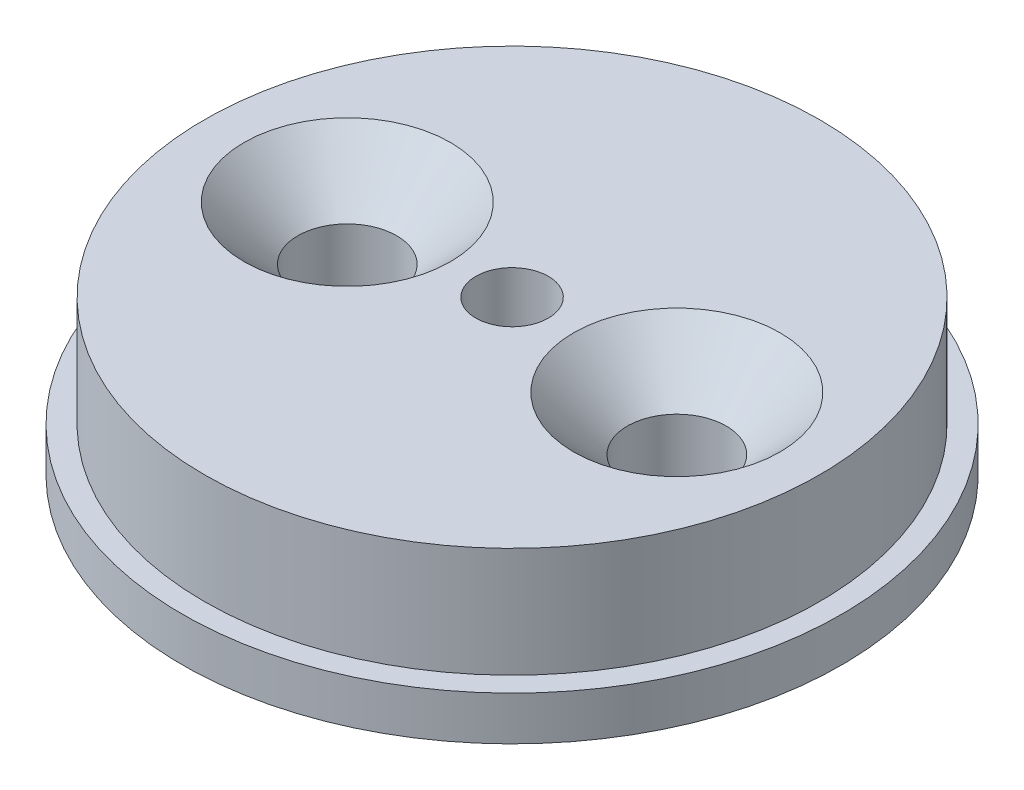
from build123d import *

# Parameters (mm, degrees)
HOLE_WIZARD_M4_1_D           = 4.5
HOLE_WIZARD_M4_1_DEPTH       = 7
HOLE_WIZARD_M4_1_CSINK_D     = 9.4
HOLE_WIZARD_M4_1_CSINK_ANGLE = 90
SKETCH_4_R                   = 3.75
CUT_EXTRUDE_M4_DEPTH         = 3
HOLE_WIZARD_M4_1_2_D         = 3.3
HOLE_WIZARD_M4_1_2_DEPTH     = 4


with BuildPart() as part:
    # 스케치1 → 회전1 (revolve)
    with BuildSketch(Plane.XY):
        Polygon((0, 0), (-15, 0), (-15, 2), (-14, 2), (-14, 7), (0, 7), align=None)
    revolve(axis=Axis((0, 0, 0), (0, 1, 0)))

    # Hole Wizard M4 _ _ _ _1
    with Locations(Plane(origin=(0, 7, 0), x_dir=(1, 0, 0), z_dir=(0, 1, 0))):
        with Locations((-7.5, 0), (7.5, 0)):
            CounterSinkHole(HOLE_WIZARD_M4_1_D / 2, HOLE_WIZARD_M4_1_CSINK_D / 2, depth=HOLE_WIZARD_M4_1_DEPTH, counter_sink_angle=HOLE_WIZARD_M4_1_CSINK_ANGLE)

    # 스케치4 → M4 둥근 머리 나사용 카운터싱크 (cut)
    with BuildSketch(Plane.XZ):
        Circle(SKETCH_4_R)
    extrude(amount=-CUT_EXTRUDE_M4_DEPTH, mode=Mode.SUBTRACT)

    # Hole Wizard M4 _ _1 2
    with Locations(Plane(origin=(0, 3, 0), x_dir=(-1, 0, 0), z_dir=(0, -1, 0))):
        with Locations((0, 0)):
            Hole(HOLE_WIZARD_M4_1_2_D / 2, depth=HOLE_WIZARD_M4_1_2_DEPTH)


solid = part.part
